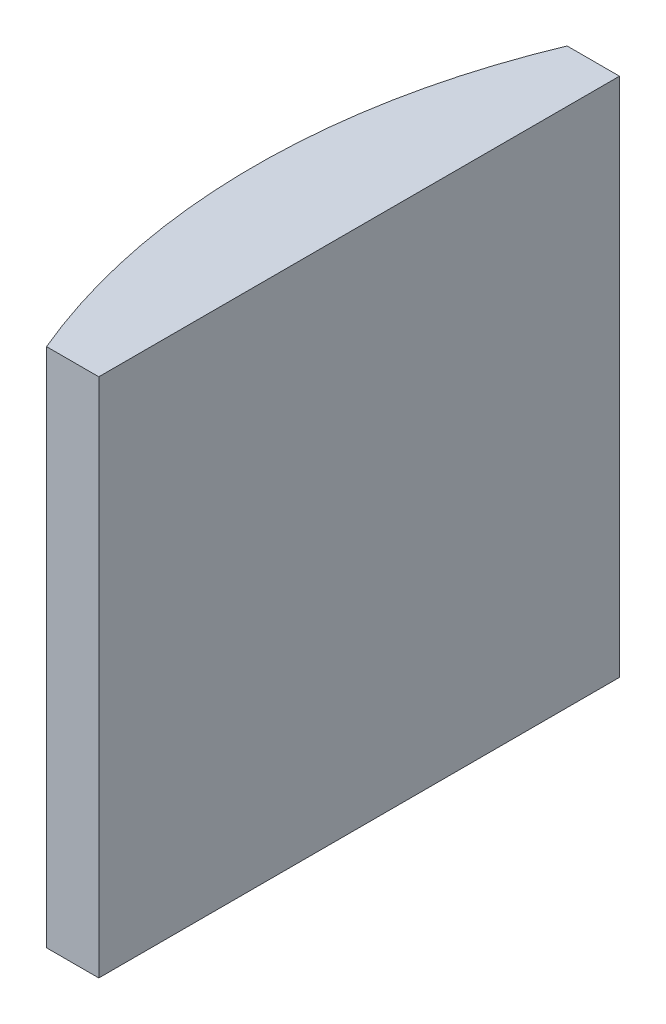
from build123d import *

# Parameters (mm, degrees)
EXTRUDE_1_DEPTH = 20


with BuildPart() as part:
    # 草图1 → 凸台-拉伸1 (new body)
    with BuildSketch(Plane(origin=(0, 0, 0), x_dir=(1, 0, 0), z_dir=(0, 1, 0))):
        with BuildLine():
            Line((-19.48221373, 10), (-17.474795665, 10))
            Line((-17.474795665, 10), (-17.474795665, -10))
            Line((-17.474795665, -10), (-19.48221373, -10))
            ThreePointArc((-19.48221373, -10), (-21.494795665, 0), (-19.48221373, 10))
        make_face()
    extrude(amount=EXTRUDE_1_DEPTH)


solid = part.part
